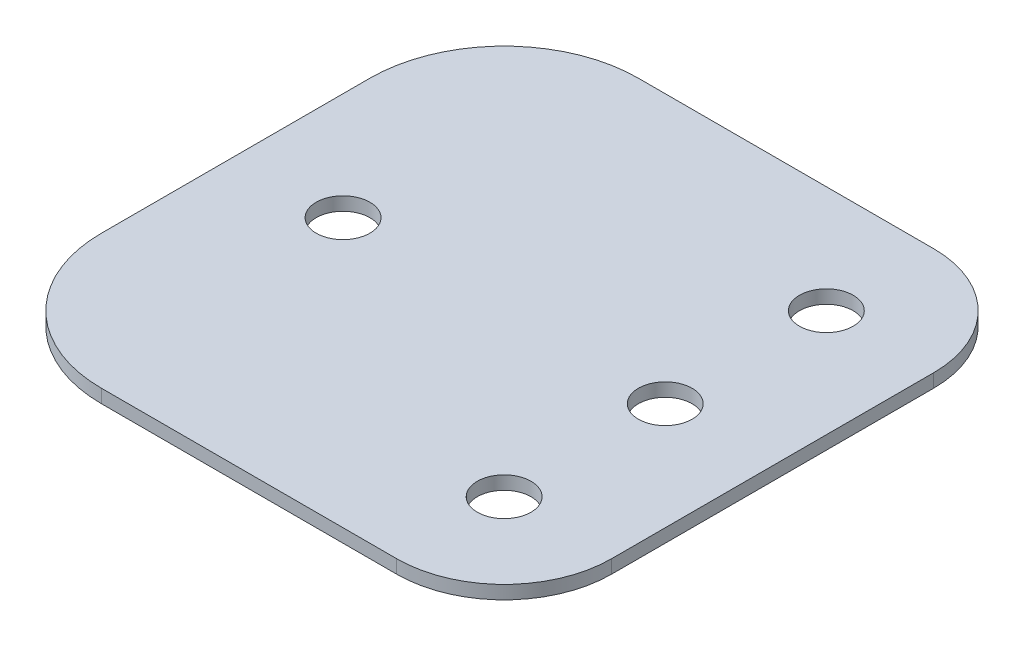
from build123d import *

# Parameters (mm, degrees)
SKETCH1_R           = 3.175
BOSS_EXTRUDE1_DEPTH = 1.5875


with BuildPart() as part:
    # Sketch1 → Boss-Extrude1 (new body)
    with BuildSketch(Plane(origin=(0, 0, 0), x_dir=(1, 0, 0), z_dir=(0, 1, 0))):
        with BuildLine():
            Line((-47.625, 0), (-12.7, 0))
            ThreePointArc((-12.7, 0), (-3.719743879, 3.719743879), (0, 12.7))
            Line((0, 12.7), (0, 50.8))
            ThreePointArc((0, 50.8), (-3.719743879, 59.780256121), (-12.7, 63.5))
            Line((-12.7, 63.5), (-47.625, 63.5))
            ThreePointArc((-47.625, 63.5), (-58.850320151, 58.850320151), (-63.5, 47.625))
            Line((-63.5, 47.625), (-63.5, 44.45))
            Line((-63.5, 44.45), (-63.5, 19.05))
            Line((-63.5, 19.05), (-63.5, 15.875))
            ThreePointArc((-63.5, 15.875), (-58.850320151, 4.649679849), (-47.625, 0))
        make_face()
        with Locations((-12.7, 12.7)):
            Circle(SKETCH1_R, mode=Mode.SUBTRACT)
        with Locations((-50.8, 31.75)):
            Circle(SKETCH1_R, mode=Mode.SUBTRACT)
        with Locations((-12.7, 31.75)):
            Circle(SKETCH1_R, mode=Mode.SUBTRACT)
        with Locations((-12.7, 50.8)):
            Circle(SKETCH1_R, mode=Mode.SUBTRACT)
    extrude(amount=BOSS_EXTRUDE1_DEPTH)


solid = part.part
